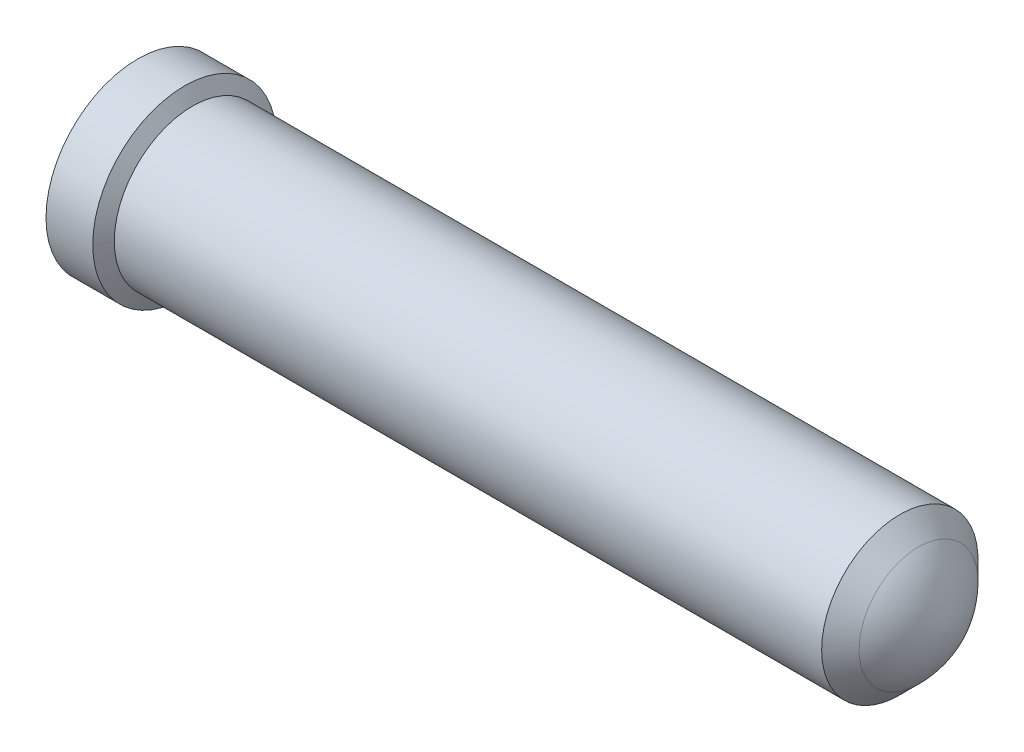
from build123d import *

# Parameters (mm, degrees)
HOLE2_D           = 0.9144
HOLE2_DEPTH       = 1.9304
HOLE2_CSINK_D     = 1.0922
HOLE2_CSINK_ANGLE = 90
HOLE2_TIP         = 0.274713475


with BuildPart() as part:
    # Sketch1 → RevolutionAngle1 (revolve)
    with BuildSketch(Plane.XY):
        with BuildLine():
            Line((0, 0), (0, 0.62357))
            Line((0, 0.62357), (0.3175, 0.62357))
            Line((0.3175, 0.62357), (0.371026143, 0.53086))
            Line((0.371026143, 0.53086), (5.175020176, 0.53086))
            Line((5.175020176, 0.53086), (5.302020176, 0.40386))
            ThreePointArc((5.302020176, 0.40386), (5.430654413, 0.218568435), (5.4864, 0))
            Line((5.4864, 0), (0, 0))
        make_face()
    revolve(axis=Axis((0, 0, 0), (1, 0, 0)))

    # Hole2
    with Locations(Plane(origin=(0, 0, 0), x_dir=(0, 0, -1), z_dir=(-1, 0, 0))):
        with Locations((0, 0)):
            CounterSinkHole(HOLE2_D / 2, HOLE2_CSINK_D / 2, depth=HOLE2_DEPTH, counter_sink_angle=HOLE2_CSINK_ANGLE)
            with Locations((0, 0, -(HOLE2_DEPTH + HOLE2_TIP / 2))):  # 118° drill point
                Cone(0, HOLE2_D / 2, HOLE2_TIP, mode=Mode.SUBTRACT)


solid = part.part
